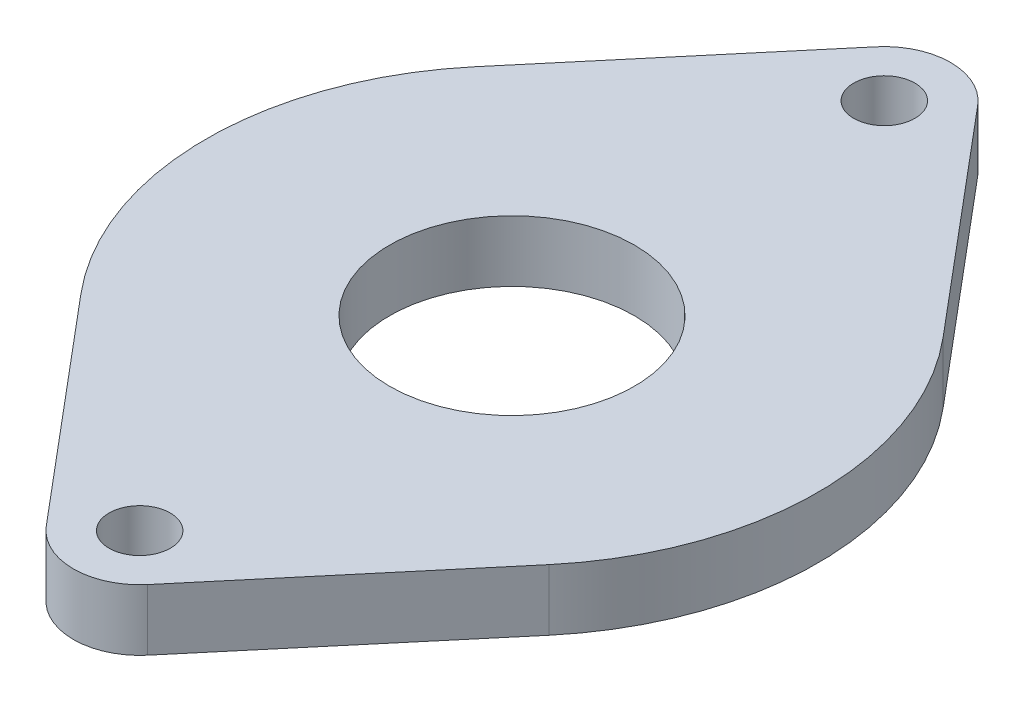
from build123d import *

# Parameters (mm, degrees)
SKETCH1_R           = 1.5
SKETCH1_R_2         = 6
BOSS_EXTRUDE1_DEPTH = 3


with BuildPart() as part:
    # Sketch1 → Boss-Extrude1 (new body)
    with BuildSketch(Plane(origin=(0, 0, 0), x_dir=(1, 0, 0), z_dir=(0, 1, 0))):
        with BuildLine():
            Line((-11.47745757, -9.657534247), (-2.486782474, -20.342465753))
            ThreePointArc((-2.486782474, -20.342465753), (0, -21.5), (2.486782474, -20.342465753))
            Line((2.486782474, -20.342465753), (11.47745757, -9.657534247))
            ThreePointArc((11.47745757, -9.657534247), (15, 0), (11.47745757, 9.657534247))
            Line((11.47745757, 9.657534247), (2.486782474, 20.342465753))
            ThreePointArc((2.486782474, 20.342465753), (0, 21.5), (-2.486782474, 20.342465753))
            Line((-2.486782474, 20.342465753), (-11.47745757, 9.657534247))
            ThreePointArc((-11.47745757, 9.657534247), (-15, 0), (-11.47745757, -9.657534247))
        make_face()
        with Locations((0, -18.25)):
            Circle(SKETCH1_R, mode=Mode.SUBTRACT)
        Circle(SKETCH1_R_2, mode=Mode.SUBTRACT)
        with Locations((0, 18.25)):
            Circle(SKETCH1_R, mode=Mode.SUBTRACT)
    extrude(amount=BOSS_EXTRUDE1_DEPTH)


solid = part.part
